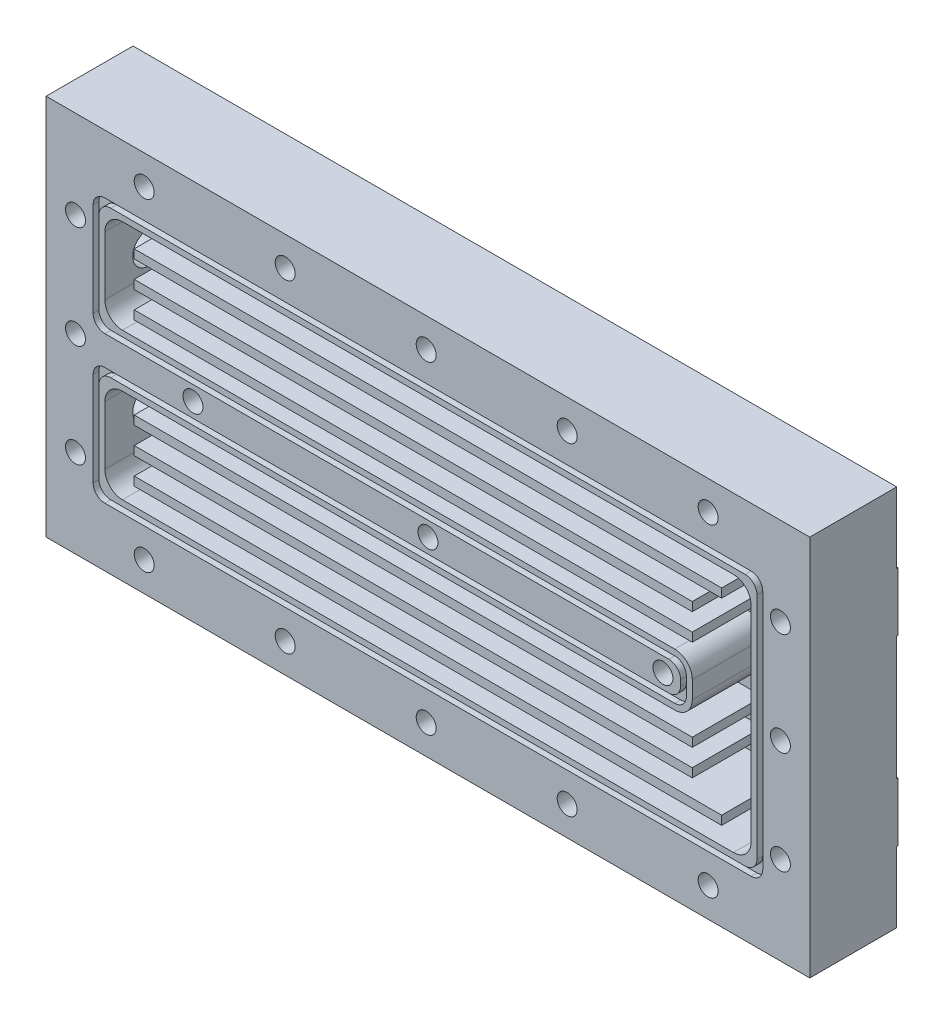
from build123d import *

# Parameters (mm, degrees)
ESQUISSE1_W             = 130
ESQUISSE1_H             = 65
BOSS_EXTRU_1_DEPTH      = 14.8
ESQUISSE13_W            = 130
ESQUISSE13_H            = 10
BOSS_EXTRU_3_DEPTH      = 0.2
D_GAGEMENT_M31_D        = 3.4
ENL_V_MAT_EXTRU_6_DEPTH = 12
D_GAGEMENT_M51_D        = 5.5
D_GAGEMENT_M51_DEPTH    = 10
ESQUISSE10_R            = 4
ENL_V_MAT_EXTRU_7_DEPTH = 2
ENL_V_MAT_EXTRU_9_DEPTH = 1
ESQUISSE12_W            = 100
ESQUISSE12_H            = 1.5
ESQUISSE12_W_2          = 95
BOSS_EXTRU_2_DEPTH      = 12
D_GAGEMENT_M32_D        = 3.4
D_GAGEMENT_M32_DEPTH    = 8.978536948
D_GAGEMENT_M32_TIP      = 1.021463052


with BuildPart() as part:
    # Esquisse1 → Boss.-Extru.1 (new body)
    with BuildSketch(Plane.XY):
        with Locations((65, 32.5)):
            Rectangle(ESQUISSE1_W, ESQUISSE1_H)
    extrude(amount=BOSS_EXTRU_1_DEPTH)

    # Esquisse13 → Boss.-Extru.3 (add)
    with BuildSketch(Plane(origin=(0, 0, 0), x_dir=(-1, 0, 0), z_dir=(0, 0, -1))):
        with Locations((-65, 48)):
            Rectangle(ESQUISSE13_W, ESQUISSE13_H)
        with Locations((-65, 17)):
            Rectangle(ESQUISSE13_W, ESQUISSE13_H)
    extrude(amount=BOSS_EXTRU_3_DEPTH)

    # Dégagement M31 (through all)
    with Locations(Plane.XY.offset(14.8)):
        with Locations((16.7, 60), (40.7, 60), (64.7, 60), (88.7, 60), (112.7, 60), (112.7, 5), (88.7, 5), (64.7, 5), (40.7, 5), (16.7, 5)):
            Hole(D_GAGEMENT_M31_D / 2)

    # Esquisse6 → Enlèv. mat.-Extru.6 (cut)
    with BuildSketch(Plane.XY.offset(14.8)):
        with BuildLine():
            Line((13, 53), (117, 53))
            ThreePointArc((117, 53), (119.121320344, 52.121320344), (120, 50))
            Line((120, 50), (120, 15))
            ThreePointArc((120, 15), (119.121320344, 12.878679656), (117, 12))
            Line((117, 12), (13, 12))
            ThreePointArc((13, 12), (10.878679656, 12.878679656), (10, 15))
            Line((10, 15), (10, 25))
            ThreePointArc((10, 25), (10.878679656, 27.121320344), (13, 28))
            Line((13, 28), (107, 28))
            ThreePointArc((107, 28), (109.121320344, 28.878679656), (110, 31))
            Line((110, 31), (110, 34))
            ThreePointArc((110, 34), (109.121320344, 36.121320344), (107, 37))
            Line((107, 37), (13, 37))
            ThreePointArc((13, 37), (10.878679656, 37.878679656), (10, 40))
            Line((10, 40), (10, 50))
            ThreePointArc((10, 50), (10.878679656, 52.121320344), (13, 53))
        make_face()
    extrude(amount=-ENL_V_MAT_EXTRU_6_DEPTH, mode=Mode.SUBTRACT)

    # Dégagement M51
    with Locations(Plane.ZY):
        with Locations((7.3, 44), (7.3, 21)):
            Hole(D_GAGEMENT_M51_D / 2, depth=D_GAGEMENT_M51_DEPTH)

    # Esquisse10 → Enlèv. mat.-Extru.7 (cut)
    with BuildSketch(Plane.ZY):
        with Locations((7.3, 21)):
            Circle(ESQUISSE10_R)
        with Locations((7.3, 44)):
            Circle(ESQUISSE10_R)
    extrude(amount=-ENL_V_MAT_EXTRU_7_DEPTH, mode=Mode.SUBTRACT)

    # Esquisse11 → Enlèv. mat.-Extru.9 (cut)
    with BuildSketch(Plane.XY.offset(14.8)):
        with BuildLine():
            Line((120, 10), (10, 10))
            ThreePointArc((10, 10), (8.585786438, 10.585786438), (8, 12))
            Line((8, 12), (8, 28))
            ThreePointArc((8, 28), (8.585786438, 29.414213562), (10, 30))
            Line((10, 30), (106, 30))
            ThreePointArc((106, 30), (107.414213562, 30.585786438), (108, 32))
            Line((108, 32), (108, 33))
            ThreePointArc((108, 33), (107.414213562, 34.414213562), (106, 35))
            Line((106, 35), (10, 35))
            ThreePointArc((10, 35), (8.585786438, 35.585786438), (8, 37))
            Line((8, 37), (8, 53))
            ThreePointArc((8, 53), (8.585786438, 54.414213562), (10, 55))
            Line((10, 55), (120, 55))
            ThreePointArc((120, 55), (121.414213562, 54.414213562), (122, 53))
            Line((122, 53), (122, 12))
            ThreePointArc((122, 12), (121.414213562, 10.585786438), (120, 10))
        make_face()
        with BuildLine():
            Line((11, 54), (119, 54))
            ThreePointArc((119, 54), (120.414213562, 53.414213562), (121, 52))
            Line((121, 52), (121, 13))
            ThreePointArc((121, 13), (120.414213562, 11.585786438), (119, 11))
            Line((119, 11), (11, 11))
            ThreePointArc((11, 11), (9.585786438, 11.585786438), (9, 13))
            Line((9, 13), (9, 27))
            ThreePointArc((9, 27), (9.585786438, 28.414213562), (11, 29))
            Line((11, 29), (107, 29))
            ThreePointArc((107, 29), (108.414213562, 29.585786438), (109, 31))
            Line((109, 31), (109, 34))
            ThreePointArc((109, 34), (108.414213562, 35.414213562), (107, 36))
            Line((107, 36), (11, 36))
            ThreePointArc((11, 36), (9.585786438, 36.585786438), (9, 38))
            Line((9, 38), (9, 52))
            ThreePointArc((9, 52), (9.585786438, 53.414213562), (11, 54))
        make_face(mode=Mode.SUBTRACT)
    extrude(amount=-ENL_V_MAT_EXTRU_9_DEPTH, mode=Mode.SUBTRACT)

    # Esquisse12 → Boss.-Extru.2 (add)
    with BuildSketch(Plane.XY.offset(2.8)):
        with Locations((65, 15.75)):
            Rectangle(ESQUISSE12_W, ESQUISSE12_H)
        with Locations((62.5, 20.25)):
            Rectangle(ESQUISSE12_W_2, ESQUISSE12_H)
        with Locations((62.5, 24.75)):
            Rectangle(ESQUISSE12_W_2, ESQUISSE12_H)
        with Locations((62.5, 40.25)):
            Rectangle(ESQUISSE12_W_2, ESQUISSE12_H)
        with Locations((62.5, 44.75)):
            Rectangle(ESQUISSE12_W_2, ESQUISSE12_H)
        with Locations((65, 49.25)):
            Rectangle(ESQUISSE12_W, ESQUISSE12_H)
    extrude(amount=BOSS_EXTRU_2_DEPTH)

    # Dégagement M32
    with Locations(Plane.XY.offset(14.8)):
        with Locations((5, 50), (5, 15), (25, 32.5), (65, 32.5), (105, 32.5), (125, 15), (125, 50), (5, 32.5), (125, 32.5)):
            Hole(D_GAGEMENT_M32_D / 2, depth=D_GAGEMENT_M32_DEPTH)
            with Locations((0, 0, -(D_GAGEMENT_M32_DEPTH + D_GAGEMENT_M32_TIP / 2))):  # 118° drill point
                Cone(0, D_GAGEMENT_M32_D / 2, D_GAGEMENT_M32_TIP, mode=Mode.SUBTRACT)


solid = part.part
